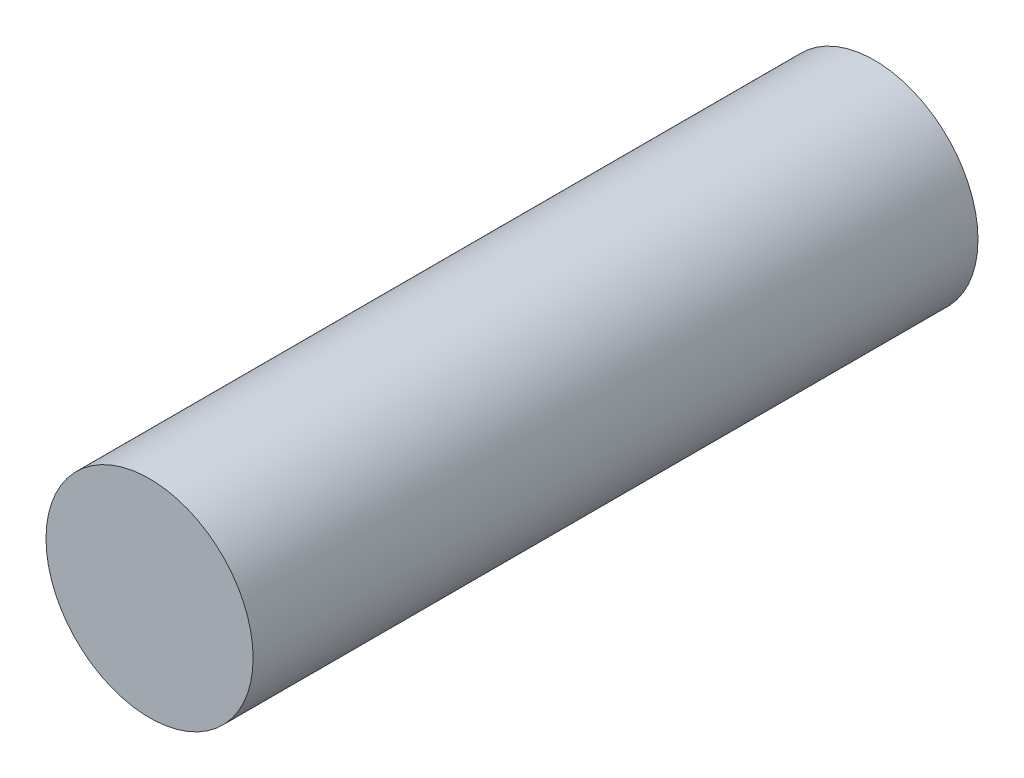
from build123d import *

# Parameters (mm, degrees)
ESQUISSE1_R        = 4
BOSS_EXTRU_1_DEPTH = 28


with BuildPart() as part:
    # Esquisse1 → Boss.-Extru.1 (new body)
    with BuildSketch(Plane.XY):
        with Locations((-383.125, -140.161341078)):
            Circle(ESQUISSE1_R)
    extrude(amount=-BOSS_EXTRU_1_DEPTH)


solid = part.part
